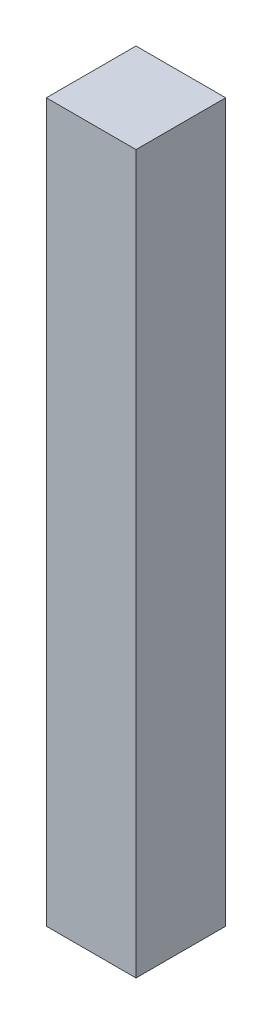
from build123d import *

# Parameters (mm, degrees)
SKETCH2_W           = 20
SKETCH2_H           = 160
BOSS_EXTRUDE1_DEPTH = 20


with BuildPart() as part:
    # Sketch2 → Boss-Extrude1 (new body)
    with BuildSketch(Plane.XY):
        with Locations((-10, -80)):
            Rectangle(SKETCH2_W, SKETCH2_H)
    extrude(amount=BOSS_EXTRUDE1_DEPTH)


solid = part.part
